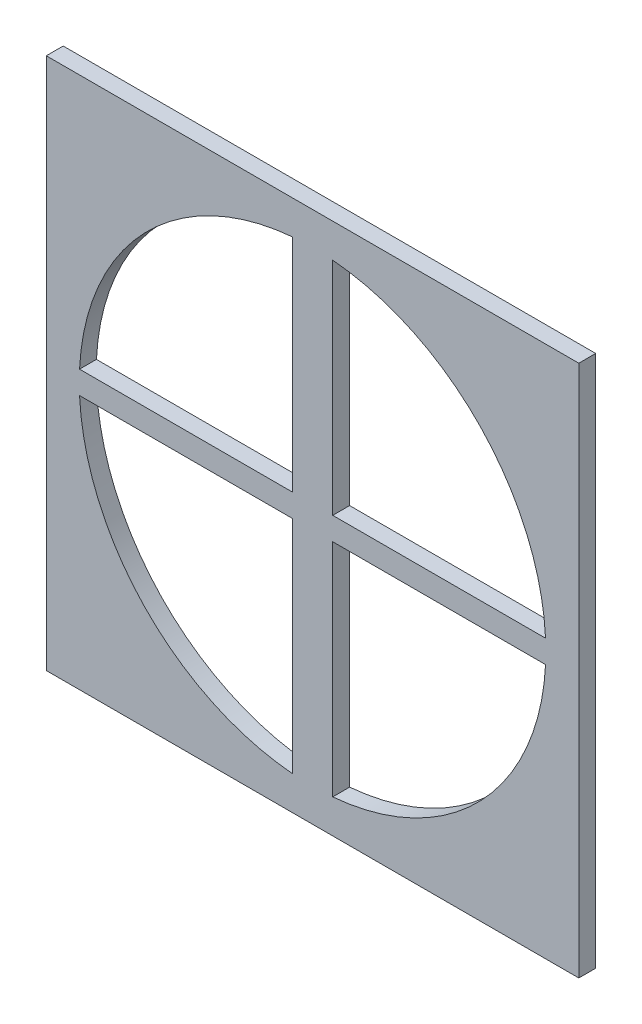
from build123d import *

# Parameters (mm, degrees)
SKETCH1_W           = 80.01
SKETCH1_H           = 80.001
BOSS_EXTRUDE1_DEPTH = 5.08
SKETCH2_R           = 35.052
CUT_EXTRUDE1_DEPTH  = 5.08
SKETCH3_W           = 3.032686736
SKETCH3_H           = 3.433230268
BOSS_EXTRUDE3_DEPTH = 5.08
SKETCH5_W           = 135.597082566
SKETCH5_H           = 106.556051774
CUT_EXTRUDE2_DEPTH  = 2.54


with BuildPart() as part:
    # Sketch1 → Boss-Extrude1 (new body)
    with BuildSketch(Plane.XY):
        Rectangle(SKETCH1_W, SKETCH1_H)
    extrude(amount=BOSS_EXTRUDE1_DEPTH)

    # Sketch2 → Cut-Extrude1 (cut)
    with BuildSketch(Plane.XY.offset(5.08)):
        Circle(SKETCH2_R)
    extrude(amount=-CUT_EXTRUDE1_DEPTH, mode=Mode.SUBTRACT)

    # Sketch3 → Boss-Extrude3 (add)
    with BuildSketch(Plane.XY.offset(5.08)):
        with BuildLine():
            ThreePointArc((3.032686736, 34.920560064), (1.517766887, 35.019124599), (0, 35.052))
            Line((0, 35.052), (0, 1.716615134))
            Line((0, 1.716615134), (3.032686736, 1.716615134))
            Line((3.032686736, 1.716615134), (3.032686736, 34.920560064))
        make_face()
        with BuildLine():
            Line((0, 1.716615134), (0, 35.052))
            ThreePointArc((0, 35.052), (-1.517766887, 35.019124599), (-3.032686736, 34.920560064))
            Line((-3.032686736, 34.920560064), (-3.032686736, 1.716615134))
            Line((-3.032686736, 1.716615134), (0, 1.716615134))
        make_face()
        with BuildLine():
            Line((-3.032686736, -1.716615134), (-3.032686736, 1.716615134))
            Line((-3.032686736, 1.716615134), (-35.009940538, 1.716615134))
            ThreePointArc((-35.009940538, 1.716615134), (-35.052, 0), (-35.009940538, -1.716615134))
            Line((-35.009940538, -1.716615134), (-3.032686736, -1.716615134))
        make_face()
        with Locations((1.516343368, 0)):
            Rectangle(SKETCH3_W, SKETCH3_H)
        with Locations((-1.516343368, 0)):
            Rectangle(SKETCH3_W, SKETCH3_H)
        with BuildLine():
            Line((3.032686736, -1.716615134), (0, -1.716615134))
            Line((0, -1.716615134), (0, -35.052))
            ThreePointArc((0, -35.052), (1.517766887, -35.019124599), (3.032686736, -34.920560064))
            Line((3.032686736, -34.920560064), (3.032686736, -1.716615134))
        make_face()
        with BuildLine():
            Line((0, -35.052), (0, -1.716615134))
            Line((0, -1.716615134), (-3.032686736, -1.716615134))
            Line((-3.032686736, -1.716615134), (-3.032686736, -34.920560064))
            ThreePointArc((-3.032686736, -34.920560064), (-1.517766887, -35.019124599), (0, -35.052))
        make_face()
        with BuildLine():
            Line((35.009940538, 1.716615134), (3.032686736, 1.716615134))
            Line((3.032686736, 1.716615134), (3.032686736, -1.716615134))
            Line((3.032686736, -1.716615134), (35.009940538, -1.716615134))
            ThreePointArc((35.009940538, -1.716615134), (35.041483557, -0.858565157), (35.052, 0))
            ThreePointArc((35.052, 0), (35.041483557, 0.858565157), (35.009940538, 1.716615134))
        make_face()
    extrude(amount=-BOSS_EXTRUDE3_DEPTH)

    # Sketch5 → Cut-Extrude2 (cut)
    with BuildSketch(Plane.XY.offset(5.08)):
        with Locations((8.610263187, -0.677600572)):
            Rectangle(SKETCH5_W, SKETCH5_H)
    extrude(amount=-CUT_EXTRUDE2_DEPTH, mode=Mode.SUBTRACT)


solid = part.part
